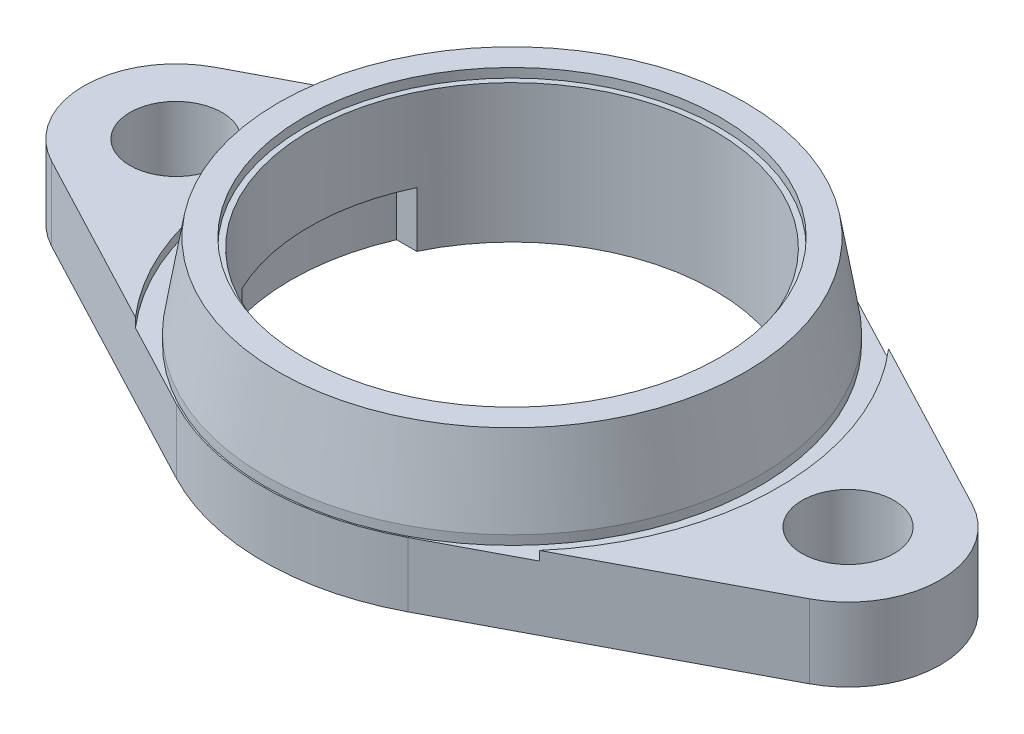
from build123d import *

# Parameters (mm, degrees)
SKETCH1_R              = 11
FLANGE_DEPTH           = 4
SKETCH3_R              = 13.425
TOP_RECESS_DEPTH       = 0.5
BOTTOM_RECESS_1_DEPTH  = 0.5
BOTTOM_RECESS_2_DEPTH  = 3
MOUNTING_HOLE_M5X0_8_D = 5


with BuildPart() as part:
    # Sketch1 → Flange (new body)
    with BuildSketch(Plane(origin=(0, 0, 0), x_dir=(1, 0, 0), z_dir=(0, 1, 0))):
        with BuildLine():
            Line((20.578767123, 4.424572712), (6.287671233, 11.946346323))
            ThreePointArc((6.287671233, 11.946346323), (0, 13.5), (-6.287671233, 11.946346323))
            Line((-6.287671233, 11.946346323), (-20.578767123, 4.424572712))
            ThreePointArc((-20.578767123, 4.424572712), (-23.25, 0), (-20.578767123, -4.424572712))
            Line((-20.578767123, -4.424572712), (-6.287671233, -11.946346323))
            ThreePointArc((-6.287671233, -11.946346323), (0, -13.5), (6.287671233, -11.946346323))
            Line((6.287671233, -11.946346323), (20.578767123, -4.424572712))
            ThreePointArc((20.578767123, -4.424572712), (23.25, 0), (20.578767123, 4.424572712))
        make_face()
        with Locations(Location((0, 0, 0), (0, 0, 270))):
            Circle(SKETCH1_R, mode=Mode.SUBTRACT)
    extrude(amount=FLANGE_DEPTH)

    # Sketch2 → Bearing Seat (revolve)
    with BuildSketch(Plane.XY, mode=Mode.PRIVATE) as bearing_seat_sk:
        Polygon((-13.425, 4), (-12.675, 8.5), (-11.3, 8.5), (-11.3, 8), (-11, 8), (-11, 4), align=None)
    revolve(bearing_seat_sk.sketch.rotate(Axis((0, 0, 0), (0, 1, 0)), 270), axis=Axis((0, 0, 0), (0, 1, 0)))

    # Sketch3 → Top Recess (cut)
    with BuildSketch(Plane(origin=(0, 4, 0), x_dir=(1, 0, 0), z_dir=(0, 1, 0))):
        with BuildLine():
            Line((10.970198855, 9.481810855), (6.287671233, 11.946346323))
            ThreePointArc((6.287671233, 11.946346323), (0, 13.5), (-6.287671233, 11.946346323))
            Line((-6.287671233, 11.946346323), (-10.970198855, 9.481810855))
            ThreePointArc((-10.970198855, 9.481810855), (-14.5, 0), (-10.970198855, -9.481810855))
            Line((-10.970198855, -9.481810855), (-6.287671233, -11.946346323))
            ThreePointArc((-6.287671233, -11.946346323), (0, -13.5), (6.287671233, -11.946346323))
            Line((6.287671233, -11.946346323), (10.970198855, -9.481810855))
            ThreePointArc((10.970198855, -9.481810855), (14.5, 0), (10.970198855, 9.481810855))
        make_face()
        with Locations(Location((0, 0, 0), (0, 0, 270))):
            Circle(SKETCH3_R, mode=Mode.SUBTRACT)
    extrude(amount=-TOP_RECESS_DEPTH, mode=Mode.SUBTRACT)

    # Sketch5 → Bottom Recess 1 (cut)
    with BuildSketch(Plane.XZ):
        with BuildLine():
            Line((17.009424329, 4.325618107), (5.47260274, 10.397745874))
            ThreePointArc((5.47260274, 10.397745874), (0, 11.75), (-5.47260274, 10.397745874))
            Line((-5.47260274, 10.397745874), (-17.009424329, 4.325618107))
            ThreePointArc((-17.009424329, 4.325618107), (-13.75, 0), (-17.009424329, -4.325618107))
            Line((-17.009424329, -4.325618107), (-5.47260274, -10.397745874))
            ThreePointArc((-5.47260274, -10.397745874), (0, -11.75), (5.47260274, -10.397745874))
            Line((5.47260274, -10.397745874), (17.009424329, -4.325618107))
            ThreePointArc((17.009424329, -4.325618107), (13.75, 0), (17.009424329, 4.325618107))
        make_face()
    extrude(amount=-BOTTOM_RECESS_1_DEPTH, mode=Mode.SUBTRACT)

    # Sketch6 → Bottom Recess 2 (cut)
    with BuildSketch(Plane.XZ.offset(-0.5)):
        with BuildLine():
            Line((-11.01986842, 4.75), (11.01986842, 4.75))
            ThreePointArc((11.01986842, 4.75), (12, 0), (11.01986842, -4.75))
            Line((11.01986842, -4.75), (-11.01986842, -4.75))
            ThreePointArc((-11.01986842, -4.75), (-12, 0), (-11.01986842, 4.75))
        make_face()
    extrude(amount=-BOTTOM_RECESS_2_DEPTH, mode=Mode.SUBTRACT)

    # Mounting Hole (M5x0.8) (through all)
    with Locations(Plane(origin=(0, 4, 0), x_dir=(1, 0, 0), z_dir=(0, 1, 0))):
        with Locations((18.25, 0), (-18.25, 0)):
            Hole(MOUNTING_HOLE_M5X0_8_D / 2)


solid = part.part
